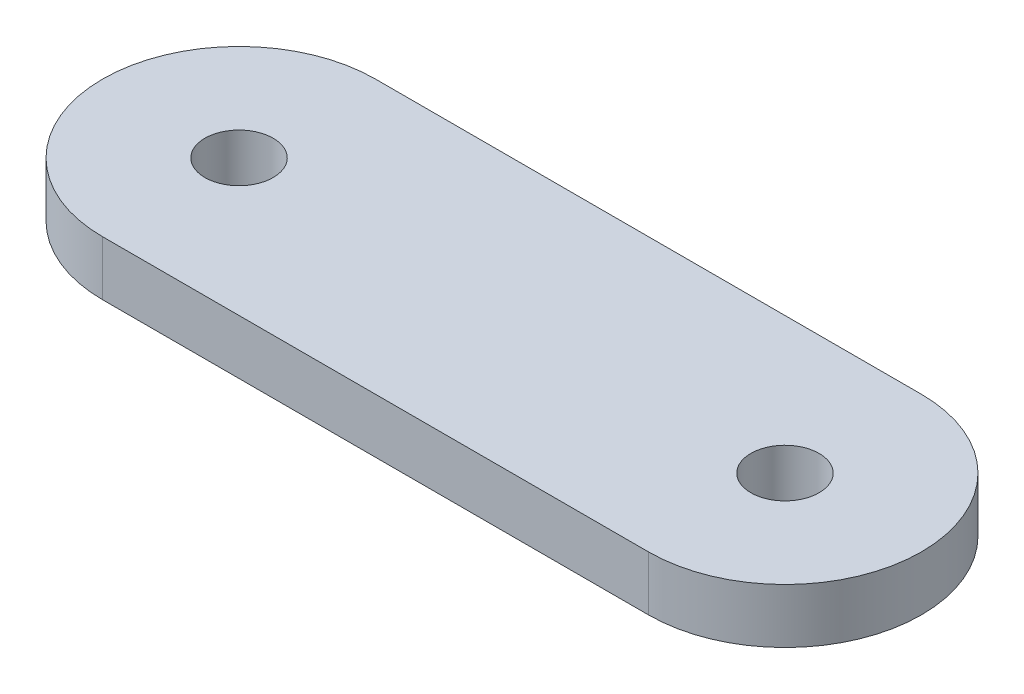
from build123d import *

# Parameters (mm, degrees)
SKETCH1_R           = 1.25
BOSS_EXTRUDE1_DEPTH = 2


with BuildPart() as part:
    # Sketch1 → Boss-Extrude1 (new body)
    with BuildSketch(Plane(origin=(0, 0, 0), x_dir=(1, 0, 0), z_dir=(0, 1, 0))):
        with BuildLine():
            Line((0, 5), (20, 5))
            ThreePointArc((20, 5), (25, 0), (20, -5))
            Line((20, -5), (0, -5))
            ThreePointArc((0, -5), (-5, 0), (0, 5))
        make_face()
        Circle(SKETCH1_R, mode=Mode.SUBTRACT)
        with Locations((20, 0)):
            Circle(SKETCH1_R, mode=Mode.SUBTRACT)
    extrude(amount=BOSS_EXTRUDE1_DEPTH)


solid = part.part
